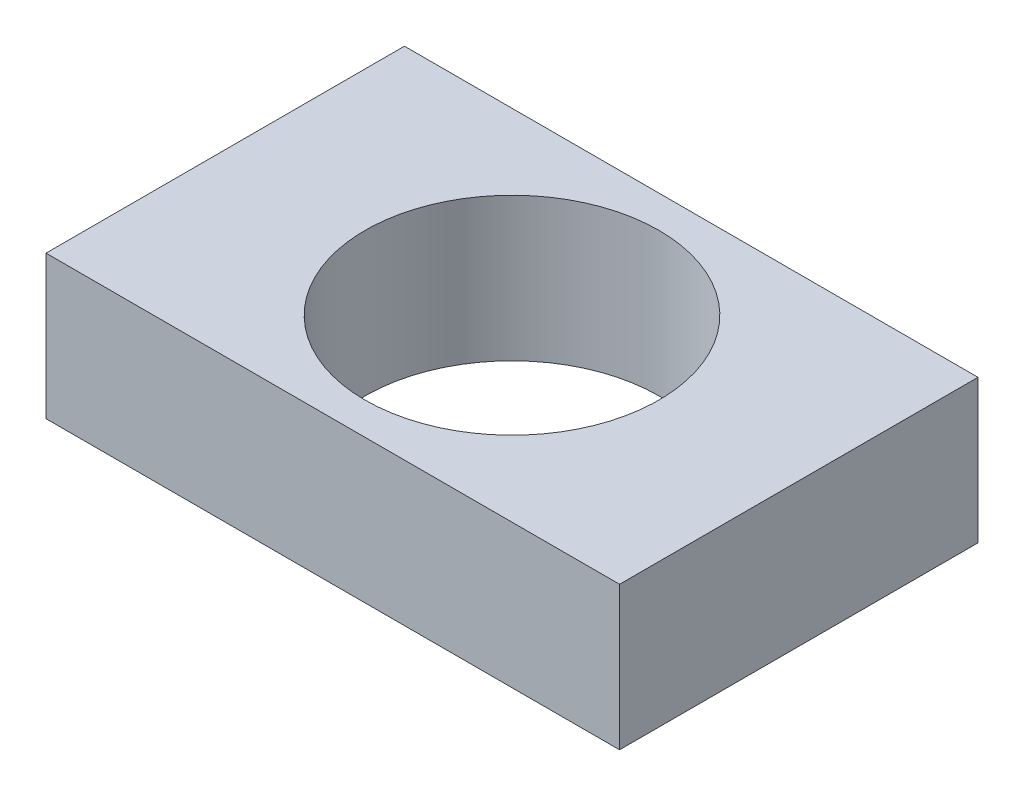
from build123d import *

# Parameters (mm, degrees)
SKETCH1_W           = 80
SKETCH1_H           = 50
BOSS_EXTRUDE1_DEPTH = 20
CUT_EXTRUDE1_REACH  = 22
SKETCH2_R           = 20.5


with BuildPart() as part:
    # Sketch1 → Boss-Extrude1 (new body)
    with BuildSketch(Plane(origin=(0, 2495.407712162, 0), x_dir=(1, 0, 0), z_dir=(0, 1, 0))):
        with Locations((-32.832129773, 17.792108153)):
            Rectangle(SKETCH1_W, SKETCH1_H)
    extrude(amount=BOSS_EXTRUDE1_DEPTH)

    # Sketch2 → Cut-Extrude1 (cut, up to next)
    with BuildSketch(Plane.XZ.offset(-2495.407712162), mode=Mode.PRIVATE) as cut_extrude1_sk1:
        with Locations((-32.832129773, -17.792108153)):
            Circle(SKETCH2_R)
    cut_extrude1_tool1 = extrude(cut_extrude1_sk1.sketch, amount=-CUT_EXTRUDE1_REACH, mode=Mode.PRIVATE) & part.part
    add(cut_extrude1_tool1.solids().sort_by_distance((-32.83213, 2495.407712, -17.792108))[0], mode=Mode.SUBTRACT)


solid = part.part
